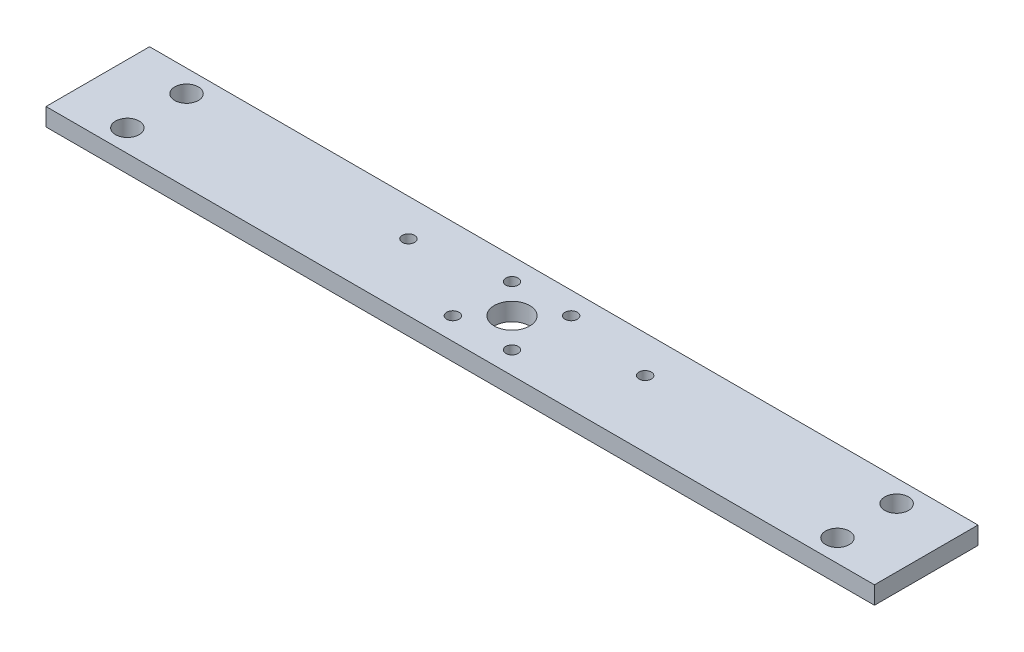
from build123d import *

# Parameters (mm, degrees)
SKETCH1_W           = 280
SKETCH1_H           = 35
SKETCH1_R           = 2.08
SKETCH1_R_2         = 6
SKETCH1_R_3         = 4
BOSS_EXTRUDE1_DEPTH = 6


with BuildPart() as part:
    # Sketch1 → Boss-Extrude1 (new body)
    with BuildSketch(Plane(origin=(0, 0, 0), x_dir=(1, 0, 0), z_dir=(0, 1, 0))):
        Rectangle(SKETCH1_W, SKETCH1_H)
        with Locations((40, 5)):
            Circle(SKETCH1_R, mode=Mode.SUBTRACT)
        with Locations((-40, 5)):
            Circle(SKETCH1_R, mode=Mode.SUBTRACT)
        Circle(SKETCH1_R_2, mode=Mode.SUBTRACT)
        with Locations((10, 10)):
            Circle(SKETCH1_R, mode=Mode.SUBTRACT)
        with Locations((-10, 10)):
            Circle(SKETCH1_R, mode=Mode.SUBTRACT)
        with Locations((-10, -10)):
            Circle(SKETCH1_R, mode=Mode.SUBTRACT)
        with Locations((10, -10)):
            Circle(SKETCH1_R, mode=Mode.SUBTRACT)
        with Locations((120, 10)):
            Circle(SKETCH1_R_3, mode=Mode.SUBTRACT)
        with Locations((-120, 10)):
            Circle(SKETCH1_R_3, mode=Mode.SUBTRACT)
        with Locations((120, -10)):
            Circle(SKETCH1_R_3, mode=Mode.SUBTRACT)
        with Locations((-120, -10)):
            Circle(SKETCH1_R_3, mode=Mode.SUBTRACT)
    extrude(amount=BOSS_EXTRUDE1_DEPTH)


solid = part.part
